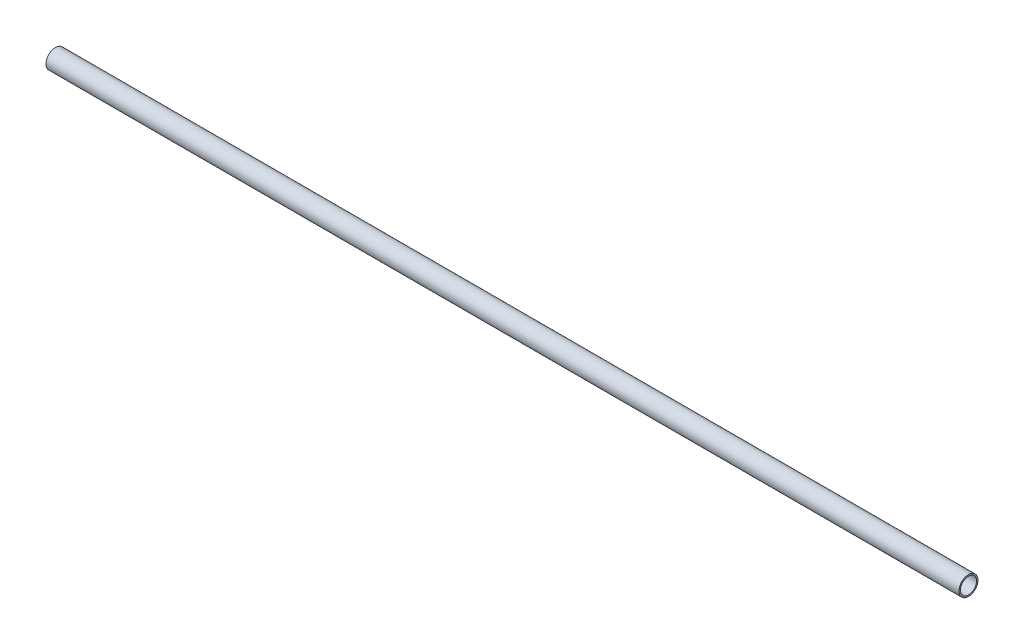
from build123d import *

# Parameters (mm, degrees)
SKETCH1_R           = 12.7
SKETCH1_R_2         = 10.795
BOSS_EXTRUDE1_DEPTH = 1219.2
SKETCH2_R           = 1.5875
CUT_EXTRUDE1_DEPTH  = 1219.2


with BuildPart() as part:
    # Sketch1 → Boss-Extrude1 (new body)
    with BuildSketch(Plane(origin=(0, 0, 0), x_dir=(0, 0, -1), z_dir=(1, 0, 0))):
        Circle(SKETCH1_R)
        Circle(SKETCH1_R_2, mode=Mode.SUBTRACT)
    extrude(amount=BOSS_EXTRUDE1_DEPTH)

    # Sketch2 → Cut-Extrude1 (cut)
    with BuildSketch(Plane.XY):
        with Locations((50.8, 0)):
            Circle(SKETCH2_R)
        with Locations((101.6, 0)):
            Circle(SKETCH2_R)
        with Locations((152.4, 0)):
            Circle(SKETCH2_R)
        with Locations((203.2, 0)):
            Circle(SKETCH2_R)
        with Locations((254, 0)):
            Circle(SKETCH2_R)
        with Locations((304.8, 0)):
            Circle(SKETCH2_R)
        with Locations((355.6, 0)):
            Circle(SKETCH2_R)
        with Locations((406.4, 0)):
            Circle(SKETCH2_R)
        with Locations((457.2, 0)):
            Circle(SKETCH2_R)
        with Locations((508, 0)):
            Circle(SKETCH2_R)
        with Locations((558.8, 0)):
            Circle(SKETCH2_R)
        with Locations((609.6, 0)):
            Circle(SKETCH2_R)
        with Locations((660.4, 0)):
            Circle(SKETCH2_R)
        with Locations((711.2, 0)):
            Circle(SKETCH2_R)
        with Locations((762, 0)):
            Circle(SKETCH2_R)
        with Locations((812.8, 0)):
            Circle(SKETCH2_R)
        with Locations((863.6, 0)):
            Circle(SKETCH2_R)
        with Locations((914.4, 0)):
            Circle(SKETCH2_R)
        with Locations((965.2, 0)):
            Circle(SKETCH2_R)
        with Locations((1016, 0)):
            Circle(SKETCH2_R)
        with Locations((1066.8, 0)):
            Circle(SKETCH2_R)
        with Locations((1117.6, 0)):
            Circle(SKETCH2_R)
        with Locations((1168.4, 0)):
            Circle(SKETCH2_R)
    extrude(amount=-CUT_EXTRUDE1_DEPTH, mode=Mode.SUBTRACT)


solid = part.part
